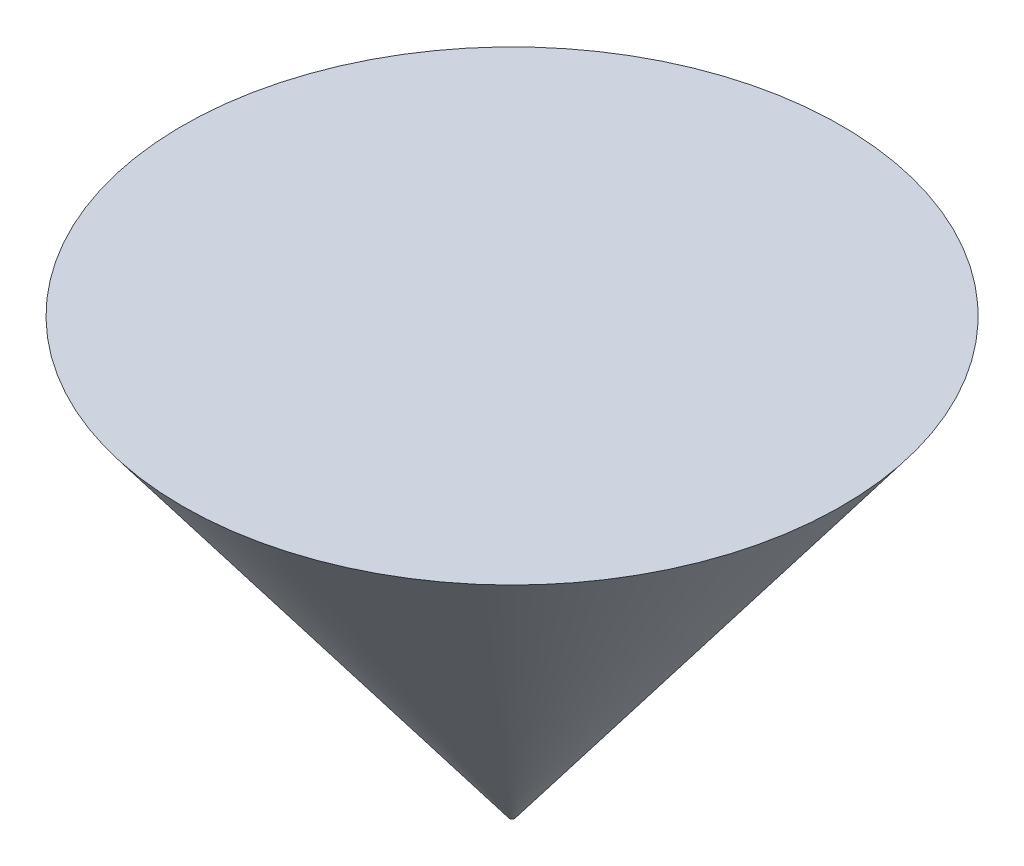
from build123d import *

# Parameters (mm, degrees)
SKETCH1_R           = 12.7
BOSS_EXTRUDE1_DEPTH = 2000
BOSS_EXTRUDE1_DRAFT = -37


with BuildPart() as part:
    # Sketch1 → Boss-Extrude1 (with draft: the straight prism first)
    with BuildSketch(Plane(origin=(0, 0, 0), x_dir=(1, 0, 0), z_dir=(0, 1, 0))):
        Circle(SKETCH1_R)
    extrude(amount=BOSS_EXTRUDE1_DEPTH)
    # Boss-Extrude1: the draft: its side faces are tilted about the plane it starts from
    boss_extrude1_sides = [part.faces().sort_by_distance(p)[0] for p in [
        (-12.7, 1000, 0),
    ]]
    draft(boss_extrude1_sides, Plane(origin=(0, 0, 0), x_dir=(1, 0, 0), z_dir=(0, 1, 0)), BOSS_EXTRUDE1_DRAFT)


solid = part.part
